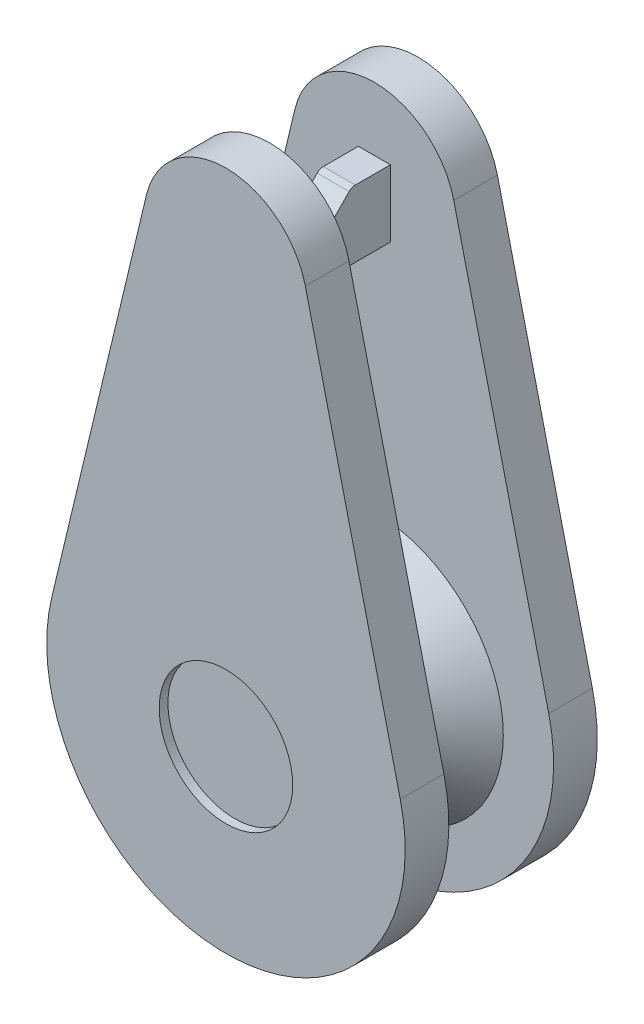
from build123d import *

# Parameters (mm, degrees)
EXTRUDE_1_DEPTH     = 1
SKETCH_3_R          = 2.952738467
SKETCH_5_R          = 1.738152606
SKETCH_6_W          = 0.733255876
SKETCH_6_H          = 1.533688363
EXTRUDE_2_DEPTH     = 2.4
CUT_EXTRUDE_1_DEPTH = 2.4
FILLET_1_R          = 0.2
FILLET_2_R          = 0.2
SKETCH_8_R          = 1.529357016
CUT_EXTRUDE_3_DEPTH = 0.2


with BuildPart() as part:
    # 草图2 → 凸台-拉伸1 (new body)
    with BuildSketch(Plane.XY):
        with BuildLine():
            Line((20.507695312, 136.955018135), (22.681412951, 146.041906443))
            ThreePointArc((22.681412951, 146.041906443), (24.498369442, 147.476769267), (26.317825582, 146.045077413))
            Line((26.317825582, 146.045077413), (28.492304397, 136.955019349))
            ThreePointArc((28.492304397, 136.955019349), (24.500000624, 131.895057082), (20.507695312, 136.955018135))
        make_face()
    extrude_1 = extrude(amount=EXTRUDE_1_DEPTH)

    # 草图3 → 放样2 section 0
    with BuildSketch(Plane.XY.offset(1)):
        with Locations((24.5, 136)):
            Circle(SKETCH_3_R)
    # 草图5 → 放样2 section 1
    with BuildSketch(Plane(origin=(0, 0, 2.2), x_dir=(-1, 0, 0), z_dir=(0, 0, -1))):
        with Locations((-24.5, 136)):
            Circle(SKETCH_5_R)
    loft_2 = loft()

    # 草图6 → 凸台-拉伸2 (add)
    with BuildSketch(Plane.XY.offset(1)):
        with Locations((24.5, 145.257576629)):
            Rectangle(SKETCH_6_W, SKETCH_6_H)
    extrude(amount=EXTRUDE_2_DEPTH)

    # 草图7 → 切除-拉伸1 (cut)
    with BuildSketch(Plane.ZY.offset(-24.133372062)):
        Polygon((1.884714406, 146.02442081), (3.4, 144.490732447), (3.4, 146.02442081), align=None)
    extrude(amount=-CUT_EXTRUDE_1_DEPTH, mode=Mode.SUBTRACT)

    # 圆角1
    fillet_1_edges = [part.edges().sort_by_distance(p)[0] for p in [
        (24.5, 144.490732447, 3.4),
        (24.5, 146.02442081, 1.884714406),
    ]]
    fillet(fillet_1_edges, radius=FILLET_1_R)

    # 镜向4: 放样2 across plane
    add(loft_2.mirror(Plane(origin=(0, 0, 2.2), x_dir=(1, 0, 0), z_dir=(0, 0, -1))))

    # 镜向5: 凸台-拉伸1 across plane
    add(extrude_1.mirror(Plane(origin=(0, 0, 2.2), x_dir=(1, 0, 0), z_dir=(0, 0, -1))))

    # 圆角2
    fillet_2_edges = [part.edges().sort_by_distance(p)[0] for p in [
        (22.761847394, 136, 2.2),
    ]]
    fillet(fillet_2_edges, radius=FILLET_2_R)

    # 草图8 → 切除-拉伸3 (cut)
    with BuildSketch(Plane.XY.offset(4.4)):
        with Locations((24.5, 136)):
            Circle(SKETCH_8_R)
    extrude(amount=-CUT_EXTRUDE_3_DEPTH, mode=Mode.SUBTRACT)


solid = part.part
